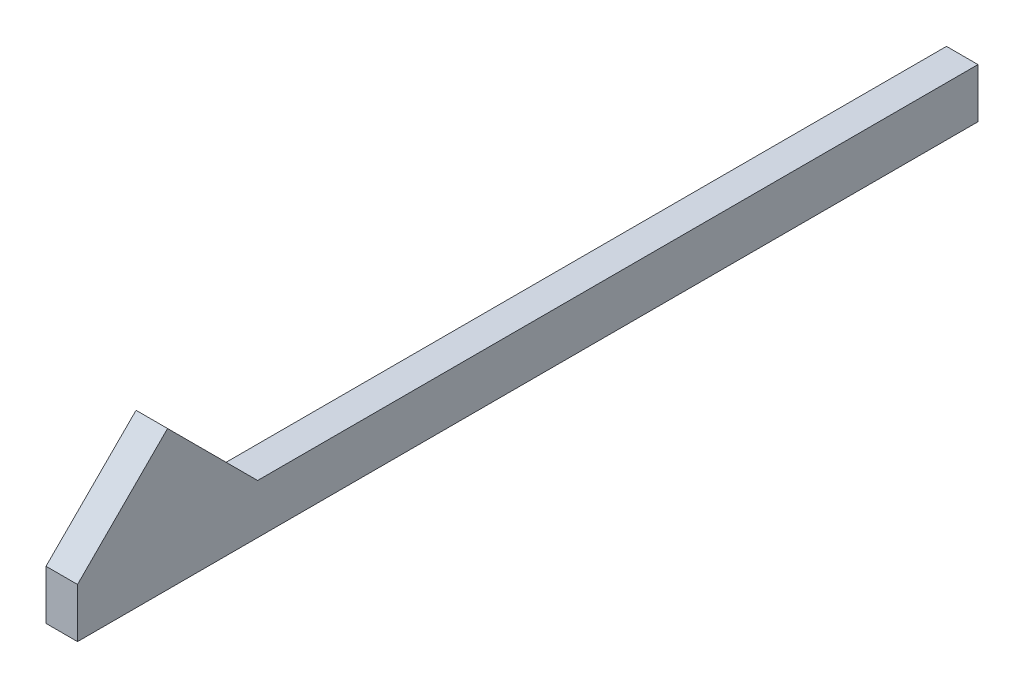
from build123d import *

# Parameters (mm, degrees)
ESQUISSE1_W        = 3.5
ESQUISSE1_H        = 5.5
BOSS_EXTRU_1_DEPTH = 100
BOSS_EXTRU_2_DEPTH = 3.5


with BuildPart() as part:
    # Esquisse1 → Boss.-Extru.1 (new body)
    with BuildSketch(Plane.XY):
        with Locations((1.75, 2.75)):
            Rectangle(ESQUISSE1_W, ESQUISSE1_H)
    extrude(amount=-BOSS_EXTRU_1_DEPTH)

    # Esquisse2 → Boss.-Extru.2 (add)
    with BuildSketch(Plane.ZY):
        Polygon((0, 5.5), (-10, 5.5), (-20, 5.5), (-10, 15.5), align=None)
    extrude(amount=-BOSS_EXTRU_2_DEPTH)


solid = part.part
